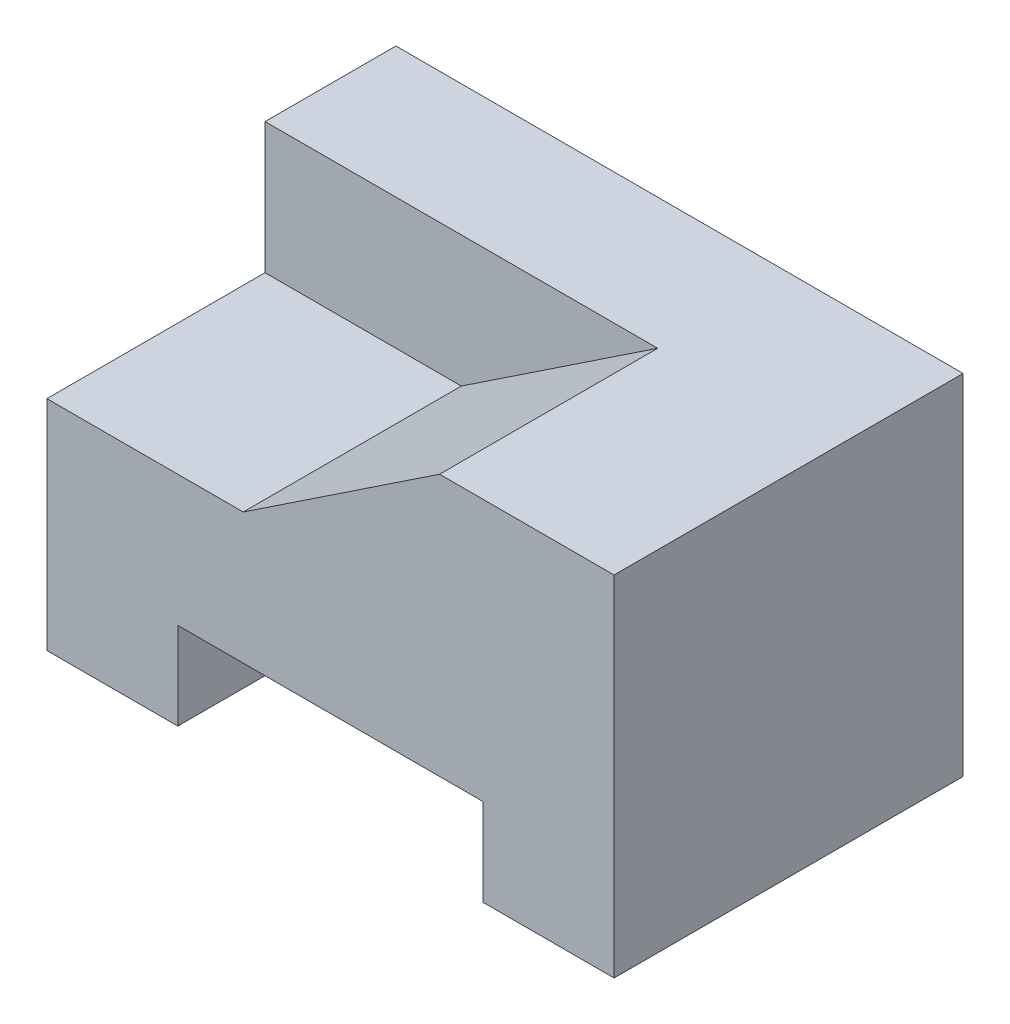
from build123d import *

# Parameters (mm, degrees)
BOSS_EXTRUDE1_DEPTH = 8
CUT_EXTRUDE1_DEPTH  = 5


with BuildPart() as part:
    # Sketch1 → Boss-Extrude1 (new body)
    with BuildSketch(Plane.XY):
        Polygon((0, 8), (0, 0), (3, 0), (3, 2), (10, 2), (10, 0), (13, 0), (13, 8), align=None)
    extrude(amount=BOSS_EXTRUDE1_DEPTH)

    # Sketch2 → Cut-Extrude1 (cut)
    with BuildSketch(Plane.XY.offset(8)):
        Polygon((9, 8), (4.5, 5), (0, 5), (0, 8), align=None)
    extrude(amount=-CUT_EXTRUDE1_DEPTH, mode=Mode.SUBTRACT)


solid = part.part
